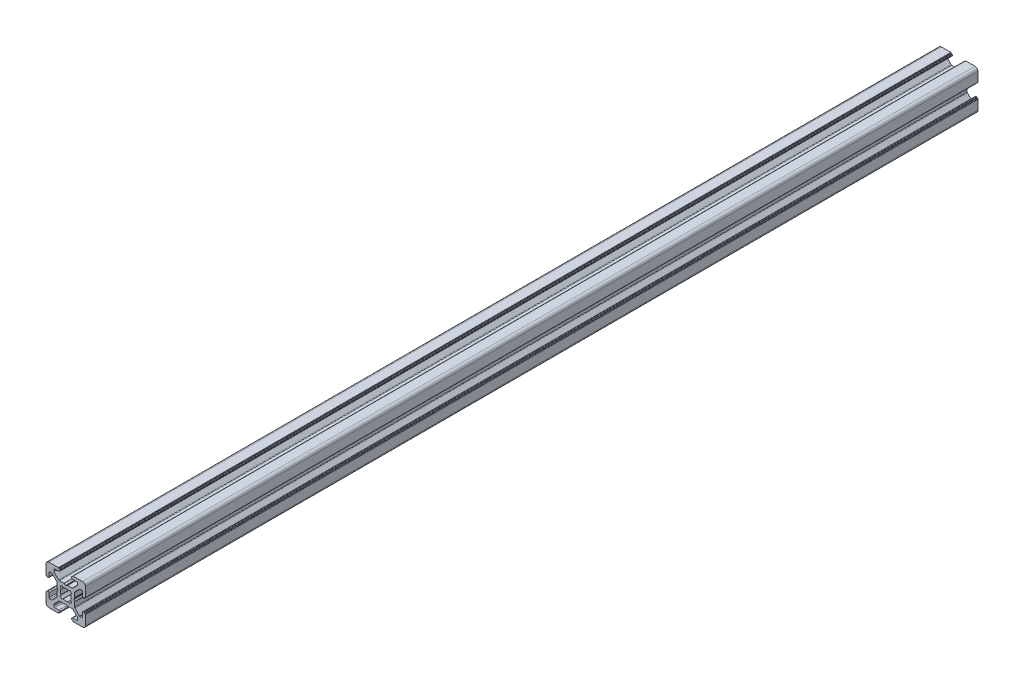
from build123d import *

# Parameters (mm, degrees)
EXTRUDE1_DEPTH = 452


with BuildPart() as part:
    # Sketch1 → Extrude1 (new body)
    with BuildSketch(Plane.XY):
        with BuildLine():
            Line((-3.5, 8.499999673), (-5.500000686, 8.499999673))
            ThreePointArc((-5.500000686, 8.499999673), (-5.853554077, 8.353553064), (-6.000000686, 7.999999673))
            Line((-6.000000686, 7.999999673), (-6.000000686, 7.267766626))
            ThreePointArc((-6.000000686, 7.267766626), (-5.961940448, 7.076424899), (-5.853554059, 6.914213219))
            Line((-5.853554059, 6.914213219), (-3.585787212, 4.646446592))
            ThreePointArc((-3.585787212, 4.646446592), (-3.423575544, 4.538060229), (-3.232233839, 4.5))
            Line((-3.232233839, 4.5), (-0.953590312, 4.5))
            ThreePointArc((-0.953590312, 4.5), (-0.901826505, 4.493185166), (-0.853590316, 4.473205083))
            Line((-0.853590316, 4.473205083), (-0.100000045, 4.038119562))
            ThreePointArc((-0.100000045, 4.038119562), (0, 4.011324632), (0.100000045, 4.038119562))
            Line((0.100000045, 4.038119562), (0.853590316, 4.473205083))
            ThreePointArc((0.853590316, 4.473205083), (0.901826505, 4.493185166), (0.953590312, 4.5))
            Line((0.953590312, 4.5), (3.232233839, 4.5))
            ThreePointArc((3.232233839, 4.5), (3.423575544, 4.538060229), (3.585787212, 4.646446592))
            Line((3.585787212, 4.646446592), (5.853554059, 6.914213219))
            ThreePointArc((5.853554059, 6.914213219), (5.961940448, 7.076424899), (6.000000686, 7.267766626))
            Line((6.000000686, 7.267766626), (6.000000686, 7.999999673))
            ThreePointArc((6.000000686, 7.999999673), (5.853554077, 8.353553064), (5.500000686, 8.499999673))
            Line((5.500000686, 8.499999673), (3.5, 8.499999673))
            ThreePointArc((3.5, 8.499999673), (3.146446609, 8.646446283), (3, 8.999999673))
            Line((3, 8.999999673), (3, 9.3))
            ThreePointArc((3, 9.3), (3.058578644, 9.441421356), (3.2, 9.5))
            Line((3.2, 9.5), (3.350000228, 9.5))
            ThreePointArc((3.350000228, 9.5), (3.491421584, 9.558578644), (3.550000228, 9.7))
            Line((3.550000228, 9.7), (3.550000228, 9.8))
            ThreePointArc((3.550000228, 9.8), (3.608578871, 9.941421356), (3.750000228, 10))
            Line((3.750000228, 10), (8.5, 10))
            ThreePointArc((8.5, 10), (9.560660172, 9.560660172), (10, 8.5))
            Line((10, 8.5), (10, 3.749999605))
            ThreePointArc((10, 3.749999605), (9.941421356, 3.608578248), (9.8, 3.549999605))
            Line((9.8, 3.549999605), (9.699999732, 3.549999605))
            ThreePointArc((9.699999732, 3.549999605), (9.558578376, 3.491420961), (9.499999732, 3.349999605))
            Line((9.499999732, 3.349999605), (9.499999732, 3.2))
            ThreePointArc((9.499999732, 3.2), (9.441421088, 3.058578644), (9.299999732, 3))
            Line((9.299999732, 3), (8.999999732, 3))
            ThreePointArc((8.999999732, 3), (8.646446341, 3.146446609), (8.499999732, 3.5))
            Line((8.499999732, 3.5), (8.499999732, 5.499999605))
            ThreePointArc((8.499999732, 5.499999605), (8.353553123, 5.853552995), (7.999999732, 5.999999605))
            Line((7.999999732, 5.999999605), (7.267766685, 5.999999605))
            ThreePointArc((7.267766685, 5.999999605), (7.076424969, 5.961939371), (6.914213294, 5.853552995))
            Line((6.914213294, 5.853552995), (4.646446398, 3.585786099))
            ThreePointArc((4.646446398, 3.585786099), (4.538060023, 3.423574425), (4.499999789, 3.232232708))
            Line((4.499999789, 3.232232708), (4.499999789, 0.953589302))
            ThreePointArc((4.499999789, 0.953589302), (4.493184953, 0.90182549), (4.473204867, 0.853589297))
            Line((4.473204867, 0.853589297), (4.038119841, 0.099999969))
            ThreePointArc((4.038119841, 0.099999969), (4.011324929, 0), (4.038119841, -0.099999969))
            Line((4.038119841, -0.099999969), (4.473204867, -0.853589297))
            ThreePointArc((4.473204867, -0.853589297), (4.493184953, -0.90182549), (4.499999789, -0.953589302))
            Line((4.499999789, -0.953589302), (4.499999789, -3.232232708))
            ThreePointArc((4.499999789, -3.232232708), (4.538060023, -3.423574425), (4.646446398, -3.585786099))
            Line((4.646446398, -3.585786099), (6.914213294, -5.853552995))
            ThreePointArc((6.914213294, -5.853552995), (7.076424969, -5.961939371), (7.267766685, -5.999999605))
            Line((7.267766685, -5.999999605), (7.999999732, -5.999999605))
            ThreePointArc((7.999999732, -5.999999605), (8.353553123, -5.853552995), (8.499999732, -5.499999605))
            Line((8.499999732, -5.499999605), (8.499999732, -3.5))
            ThreePointArc((8.499999732, -3.5), (8.646446341, -3.146446609), (8.999999732, -3))
            Line((8.999999732, -3), (9.299999732, -3))
            ThreePointArc((9.299999732, -3), (9.441421088, -3.058578644), (9.499999732, -3.2))
            Line((9.499999732, -3.2), (9.499999732, -3.349999605))
            ThreePointArc((9.499999732, -3.349999605), (9.558578376, -3.491420961), (9.699999732, -3.549999605))
            Line((9.699999732, -3.549999605), (9.8, -3.549999605))
            ThreePointArc((9.8, -3.549999605), (9.941421356, -3.608578248), (10, -3.749999605))
            Line((10, -3.749999605), (10, -8.5))
            ThreePointArc((10, -8.5), (9.560660172, -9.560660172), (8.5, -10))
            Line((8.5, -10), (3.750000228, -10))
            ThreePointArc((3.750000228, -10), (3.608578871, -9.941421356), (3.550000228, -9.8))
            Line((3.550000228, -9.8), (3.550000228, -9.7))
            ThreePointArc((3.550000228, -9.7), (3.491421584, -9.558578644), (3.350000228, -9.5))
            Line((3.350000228, -9.5), (3.2, -9.5))
            ThreePointArc((3.2, -9.5), (3.058578644, -9.441421356), (3, -9.3))
            Line((3, -9.3), (3, -8.999999673))
            ThreePointArc((3, -8.999999673), (3.146446609, -8.646446283), (3.5, -8.499999673))
            Line((3.5, -8.499999673), (5.500000686, -8.499999673))
            ThreePointArc((5.500000686, -8.499999673), (5.853554077, -8.353553064), (6.000000686, -7.999999673))
            Line((6.000000686, -7.999999673), (6.000000686, -7.267766626))
            ThreePointArc((6.000000686, -7.267766626), (5.961940448, -7.076424899), (5.853554059, -6.914213219))
            Line((5.853554059, -6.914213219), (3.585787212, -4.646446592))
            ThreePointArc((3.585787212, -4.646446592), (3.423575544, -4.538060229), (3.232233839, -4.5))
            Line((3.232233839, -4.5), (0.953590312, -4.5))
            ThreePointArc((0.953590312, -4.5), (0.901826505, -4.493185166), (0.853590316, -4.473205083))
            Line((0.853590316, -4.473205083), (0.100000045, -4.038119562))
            ThreePointArc((0.100000045, -4.038119562), (0, -4.011324632), (-0.100000045, -4.038119562))
            Line((-0.100000045, -4.038119562), (-0.853590316, -4.473205083))
            ThreePointArc((-0.853590316, -4.473205083), (-0.901826505, -4.493185166), (-0.953590312, -4.5))
            Line((-0.953590312, -4.5), (-3.232233839, -4.5))
            ThreePointArc((-3.232233839, -4.5), (-3.423575544, -4.538060229), (-3.585787212, -4.646446592))
            Line((-3.585787212, -4.646446592), (-5.853554059, -6.914213219))
            ThreePointArc((-5.853554059, -6.914213219), (-5.961940448, -7.076424899), (-6.000000686, -7.267766626))
            Line((-6.000000686, -7.267766626), (-6.000000686, -7.999999673))
            ThreePointArc((-6.000000686, -7.999999673), (-5.853554077, -8.353553064), (-5.500000686, -8.499999673))
            Line((-5.500000686, -8.499999673), (-3.5, -8.499999673))
            ThreePointArc((-3.5, -8.499999673), (-3.146446609, -8.646446283), (-3, -8.999999673))
            Line((-3, -8.999999673), (-3, -9.3))
            ThreePointArc((-3, -9.3), (-3.058578644, -9.441421356), (-3.2, -9.5))
            Line((-3.2, -9.5), (-3.350000228, -9.5))
            ThreePointArc((-3.350000228, -9.5), (-3.491421584, -9.558578644), (-3.550000228, -9.7))
            Line((-3.550000228, -9.7), (-3.550000228, -9.8))
            ThreePointArc((-3.550000228, -9.8), (-3.608578871, -9.941421356), (-3.750000228, -10))
            Line((-3.750000228, -10), (-8.5, -10))
            ThreePointArc((-8.5, -10), (-9.560660172, -9.560660172), (-10, -8.5))
            Line((-10, -8.5), (-10, -3.749999605))
            ThreePointArc((-10, -3.749999605), (-9.941421356, -3.608578248), (-9.8, -3.549999605))
            Line((-9.8, -3.549999605), (-9.699999732, -3.549999605))
            ThreePointArc((-9.699999732, -3.549999605), (-9.558578376, -3.491420961), (-9.499999732, -3.349999605))
            Line((-9.499999732, -3.349999605), (-9.499999732, -3.2))
            ThreePointArc((-9.499999732, -3.2), (-9.441421088, -3.058578644), (-9.299999732, -3))
            Line((-9.299999732, -3), (-8.999999732, -3))
            ThreePointArc((-8.999999732, -3), (-8.646446341, -3.146446609), (-8.499999732, -3.5))
            Line((-8.499999732, -3.5), (-8.499999732, -5.499999605))
            ThreePointArc((-8.499999732, -5.499999605), (-8.353553123, -5.853552995), (-7.999999732, -5.999999605))
            Line((-7.999999732, -5.999999605), (-7.267766685, -5.999999605))
            ThreePointArc((-7.267766685, -5.999999605), (-7.076424969, -5.961939371), (-6.914213294, -5.853552995))
            Line((-6.914213294, -5.853552995), (-4.646446398, -3.585786099))
            ThreePointArc((-4.646446398, -3.585786099), (-4.538060023, -3.423574425), (-4.499999789, -3.232232708))
            Line((-4.499999789, -3.232232708), (-4.499999789, -0.953589302))
            ThreePointArc((-4.499999789, -0.953589302), (-4.493184953, -0.90182549), (-4.473204867, -0.853589297))
            Line((-4.473204867, -0.853589297), (-4.038119841, -0.099999969))
            ThreePointArc((-4.038119841, -0.099999969), (-4.011324929, 0), (-4.038119841, 0.099999969))
            Line((-4.038119841, 0.099999969), (-4.473204867, 0.853589297))
            ThreePointArc((-4.473204867, 0.853589297), (-4.493184953, 0.90182549), (-4.499999789, 0.953589302))
            Line((-4.499999789, 0.953589302), (-4.499999789, 3.232232708))
            ThreePointArc((-4.499999789, 3.232232708), (-4.538060023, 3.423574425), (-4.646446398, 3.585786099))
            Line((-4.646446398, 3.585786099), (-6.914213294, 5.853552995))
            ThreePointArc((-6.914213294, 5.853552995), (-7.076424969, 5.961939371), (-7.267766685, 5.999999605))
            Line((-7.267766685, 5.999999605), (-7.999999732, 5.999999605))
            ThreePointArc((-7.999999732, 5.999999605), (-8.353553123, 5.853552995), (-8.499999732, 5.499999605))
            Line((-8.499999732, 5.499999605), (-8.499999732, 3.5))
            ThreePointArc((-8.499999732, 3.5), (-8.646446341, 3.146446609), (-8.999999732, 3))
            Line((-8.999999732, 3), (-9.299999732, 3))
            ThreePointArc((-9.299999732, 3), (-9.441421088, 3.058578644), (-9.499999732, 3.2))
            Line((-9.499999732, 3.2), (-9.499999732, 3.349999605))
            ThreePointArc((-9.499999732, 3.349999605), (-9.558578376, 3.491420961), (-9.699999732, 3.549999605))
            Line((-9.699999732, 3.549999605), (-9.8, 3.549999605))
            ThreePointArc((-9.8, 3.549999605), (-9.941421356, 3.608578248), (-10, 3.749999605))
            Line((-10, 3.749999605), (-10, 8.5))
            ThreePointArc((-10, 8.5), (-9.560660172, 9.560660172), (-8.5, 10))
            Line((-8.5, 10), (-3.750000228, 10))
            ThreePointArc((-3.750000228, 10), (-3.608578871, 9.941421356), (-3.550000228, 9.8))
            Line((-3.550000228, 9.8), (-3.550000228, 9.7))
            ThreePointArc((-3.550000228, 9.7), (-3.491421584, 9.558578644), (-3.350000228, 9.5))
            Line((-3.350000228, 9.5), (-3.2, 9.5))
            ThreePointArc((-3.2, 9.5), (-3.058578644, 9.441421356), (-3, 9.3))
            Line((-3, 9.3), (-3, 8.999999673))
            ThreePointArc((-3, 8.999999673), (-3.146446609, 8.646446283), (-3.5, 8.499999673))
        make_face()
        with BuildLine():
            Line((-1.258185436, 2.445295362), (-1.91389502, 2.989640962))
            ThreePointArc((-1.91389502, 2.989640962), (-2.511737261, 2.508410485), (-2.992174953, 1.909930962))
            Line((-2.992174953, 1.909930962), (-2.445295423, 1.258185317))
            ThreePointArc((-2.445295423, 1.258185317), (-2.75, 0), (-2.445295423, -1.258185317))
            Line((-2.445295423, -1.258185317), (-2.992174953, -1.909930962))
            ThreePointArc((-2.992174953, -1.909930962), (-2.511737261, -2.508410485), (-1.91389502, -2.989640962))
            Line((-1.91389502, -2.989640962), (-1.258185436, -2.445295362))
            ThreePointArc((-1.258185436, -2.445295362), (0, -2.75), (1.258185436, -2.445295362))
            Line((1.258185436, -2.445295362), (1.91389502, -2.989640962))
            ThreePointArc((1.91389502, -2.989640962), (2.511737261, -2.508410485), (2.992174953, -1.909930962))
            Line((2.992174953, -1.909930962), (2.445295423, -1.258185317))
            ThreePointArc((2.445295423, -1.258185317), (2.75, 0), (2.445295423, 1.258185317))
            Line((2.445295423, 1.258185317), (2.992174953, 1.909930962))
            ThreePointArc((2.992174953, 1.909930962), (2.511737261, 2.508410485), (1.91389502, 2.989640962))
            Line((1.91389502, 2.989640962), (1.258185436, 2.445295362))
            ThreePointArc((1.258185436, 2.445295362), (0, 2.75), (-1.258185436, 2.445295362))
        make_face(mode=Mode.SUBTRACT)
    extrude(amount=EXTRUDE1_DEPTH)


solid = part.part
